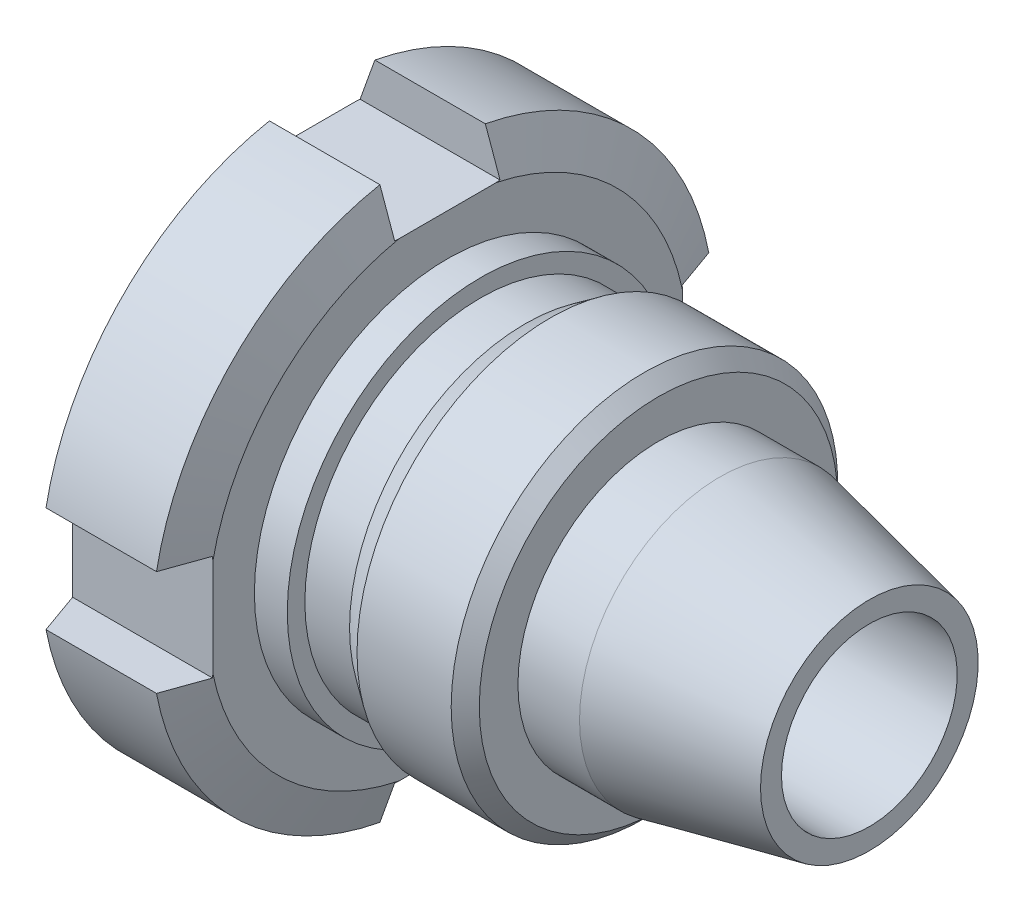
from build123d import *

# Parameters (mm, degrees)
CUT_EXTRUDE1_START = -12.700006
CUT_EXTRUDE1_DEPTH = 12.700012
CIRPATTERN1_COUNT  = 4


with BuildPart() as part:
    # Sketch1 → Revolve1 (revolve)
    with BuildSketch(Plane.XY):
        Polygon((0, 6.35), (0, 21.6662), (1.358992061, 25.4), (11.341007939, 25.4), (12.7, 21.6662), (12.7, 17.4625), (15.6718, 17.4625), (15.6718, 15.875), (19.7104, 15.875), (21.971, 17.4625), (30.48, 17.4625), (31.75, 16.1925), (31.75, 12.7), (37.3126, 12.7), (50.8, 9.83316463), (50.8, 7.9375), (38.1, 7.9375), (37.146133767, 6.35), align=None)
    revolve(axis=Axis((0, 0, 0), (1, 0, 0)))

    # Sketch2 → Cut-Extrude1 (cut)
    with BuildSketch(Plane.ZY.offset(CUT_EXTRUDE1_START)):
        with BuildLine():
            Line((-4.7625, 21.215720912), (-4.7625, 24.949520912))
            ThreePointArc((-4.7625, 24.949520912), (0, 25.4), (4.7625, 24.949520912))
            Line((4.7625, 24.949520912), (4.7625, 21.215720912))
            Line((4.7625, 21.215720912), (-4.7625, 21.215720912))
        make_face()
    cut_extrude1 = extrude(amount=CUT_EXTRUDE1_DEPTH, mode=Mode.SUBTRACT)

    # CirPattern1: Cut-Extrude1 ×4 about axis
    cirpattern1_axis = Axis((0, 0, 0), (1, 0, 0))
    for i in range(1, CIRPATTERN1_COUNT):
        add(cut_extrude1.rotate(cirpattern1_axis, i * 360 / CIRPATTERN1_COUNT), mode=Mode.SUBTRACT)


solid = part.part
